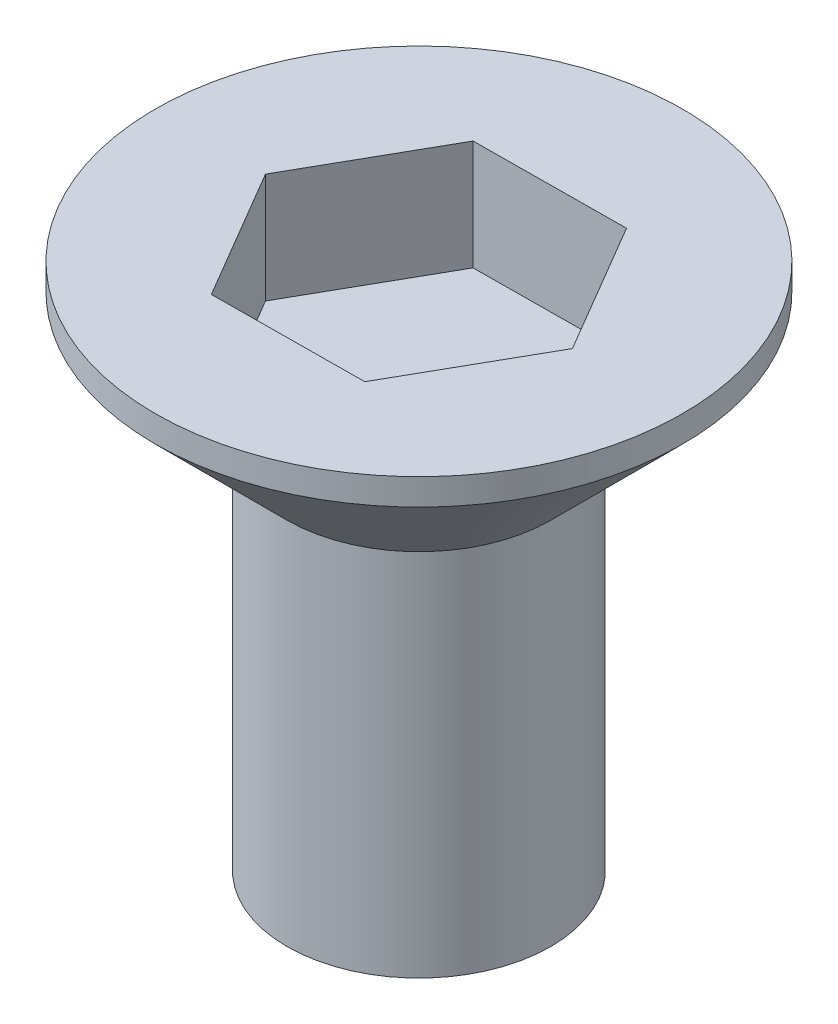
from build123d import *

# Parameters (mm, degrees)
CUT_EXTRUDE_1_DEPTH = 2.5


with BuildPart() as part:
    # Эскиз1 → Повернуть1 (revolve)
    with BuildSketch(Plane.XY):
        Polygon((0, 0), (3, 0), (3, 8.4), (6, 11.4), (6, 12), (0, 12), align=None)
    revolve(axis=Axis((0, 68.644575989, 0), (0, -1, 0)))

    # Эскиз2 → Вырез-Вытянуть1 (cut)
    with BuildSketch(Plane(origin=(0, 12, 0), x_dir=(1, 0, 0), z_dir=(0, 1, 0))):
        Polygon((1.755265403, -2.986476748), (3.463997433, 0.026866056), (1.708732029, 3.013342804), (-1.755265403, 2.986476748), (-3.463997433, -0.026866056), (-1.708732029, -3.013342804), align=None)
    extrude(amount=-CUT_EXTRUDE_1_DEPTH, mode=Mode.SUBTRACT)


solid = part.part
